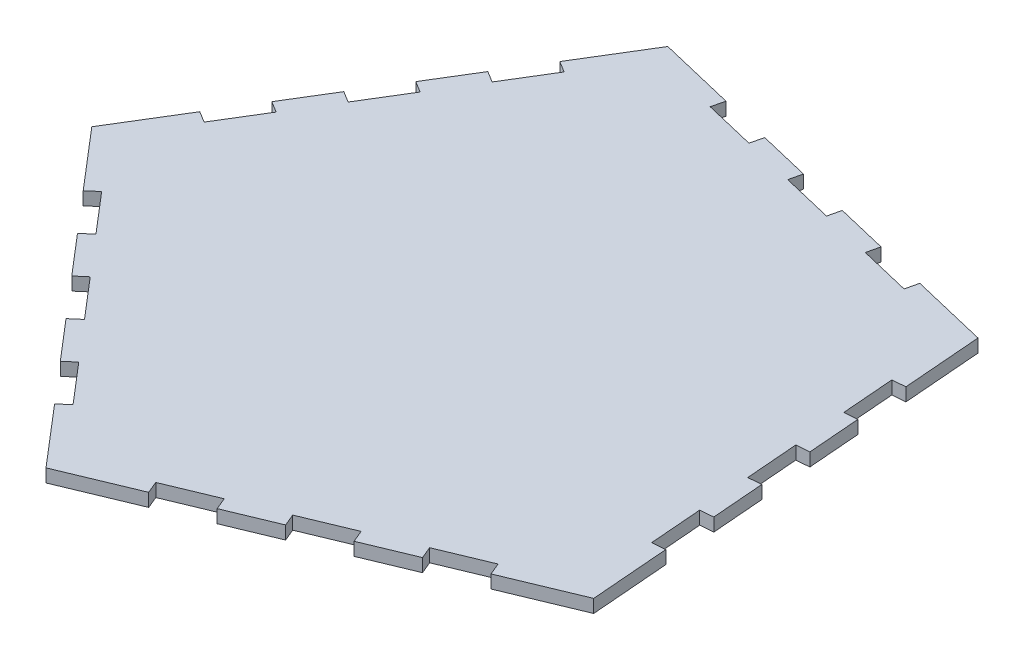
from build123d import *

# Parameters (mm, degrees)
BOSS_EXTRUDE1_DEPTH = 6.35
CUT_EXTRUDE1_DEPTH  = 7.35


with BuildPart() as part:
    # Sketch1 → Boss-Extrude1 (new body)
    with BuildSketch(Plane(origin=(0, 0, 0), x_dir=(1, 0, 0), z_dir=(0, 1, 0))):
        Polygon((67.038031479, -56.883887939), (50.857913673, 145.670904124), (-146.783072598, 192.87557069), (-252.751801878, 19.494866992), (-120.603092047, -134.864967453), align=None)
    extrude(amount=BOSS_EXTRUDE1_DEPTH)

    # Sketch2 → Cut-Extrude1 (cut, through all)
    with BuildSketch(Plane(origin=(0, 6.35, 0), x_dir=(1, 0, 0), z_dir=(0, 1, 0))):
        Polygon((-87.85729012, -114.379729934), (-64.40214968, -104.632094995), (-61.965240945, -110.495880105), (-85.420381385, -120.243515044), align=None)
        Polygon((-38.510100504, -100.748245166), (-15.054960063, -91.000610226), (-17.491868798, -85.136825116), (-40.947009239, -94.884460055), align=None)
        Polygon((8.400180377, -81.252975287), (31.855320818, -71.505340348), (29.418412083, -65.641555238), (5.963271643, -75.389190177), align=None)
        Polygon((-223.150173958, -5.317954784), (-206.631585229, -24.61293409), (-211.455330056, -28.742581272), (-227.973918785, -9.447601966), align=None)
        Polygon((-194.936741327, -48.037560577), (-190.112996501, -43.907913395), (-173.594407772, -63.202892701), (-178.418152598, -67.332539883), align=None)
        Polygon((-161.899563869, -86.627519189), (-157.075819043, -82.497872006), (-140.557230314, -101.792851312), (-145.38097514, -105.922498494), align=None)
        Polygon((-161.234062348, 157.055165957), (-174.480153508, 135.382577994), (-179.898300498, 138.694100784), (-166.652209338, 160.366688747), align=None)
        Polygon((-193.144391658, 117.021512822), (-187.726244668, 113.709990032), (-200.972335828, 92.03740207), (-206.390482818, 95.34892486), align=None)
        Polygon((-219.636573978, 73.676336898), (-214.218426988, 70.364814108), (-227.464518148, 48.692226145), (-232.882665138, 52.003748935), align=None)
        Polygon((12.325082917, 148.345498284), (-12.380040367, 154.246081605), (-10.904894536, 160.422362426), (13.800228747, 154.521779105), align=None)
        Polygon((-35.61001782, 166.322945747), (-37.085163651, 160.146664926), (-61.790286935, 166.047248246), (-60.315141104, 172.223529067), align=None)
        Polygon((-85.020264388, 178.124112388), (-86.495410219, 171.947831567), (-111.200533502, 177.848414888), (-109.725387672, 184.024695709), align=None)
        Polygon((57.674422139, -19.410493109), (55.651907413, 5.908855899), (61.981744665, 6.41448458), (64.004259391, -18.904864428), align=None)
        Polygon((59.959229939, 31.733833588), (53.629392687, 31.228204907), (51.606877961, 56.547553915), (57.936715213, 57.053182596), align=None)
        Polygon((55.914200488, 82.372531604), (49.584363236, 81.866902923), (47.56184851, 107.186251931), (53.891685762, 107.691880612), align=None)
    extrude(amount=-CUT_EXTRUDE1_DEPTH, mode=Mode.SUBTRACT)


solid = part.part
